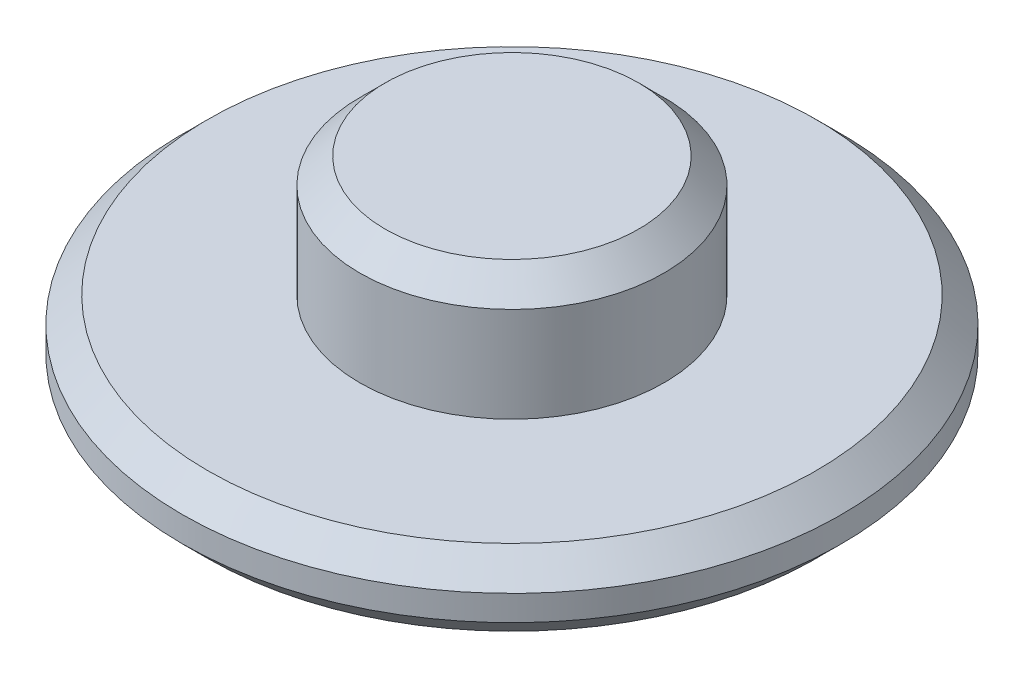
from build123d import *

# Parameters (mm, degrees)
CROQUIS1_R              = 6
SALIENTE_EXTRUIR1_DEPTH = 4.75
CROQUIS1_3_R            = 13
SALIENTE_EXTRUIR2_DEPTH = 3
CHAFL_N1_SIZE           = 1


with BuildPart() as part:
    # Croquis1 → Saliente-Extruir1 (new body)
    with BuildSketch(Plane(origin=(0, 0, 0), x_dir=(1, 0, 0), z_dir=(0, 1, 0))):
        Circle(CROQUIS1_R)
    extrude(amount=SALIENTE_EXTRUIR1_DEPTH)

    # Croquis1_3 → Saliente-Extruir2 (add)
    with BuildSketch(Plane(origin=(0, 0, 0), x_dir=(1, 0, 0), z_dir=(0, 1, 0))):
        Circle(CROQUIS1_3_R)
    extrude(amount=-SALIENTE_EXTRUIR2_DEPTH)

    # Chaflán1
    chafl_n1_edges = [part.edges().sort_by_distance(p)[0] for p in [
        (-6, 4.75, 0),
        (-13, -3, 0),
        (-13, 0, 0),
    ]]
    chamfer(chafl_n1_edges, length=CHAFL_N1_SIZE)


solid = part.part
